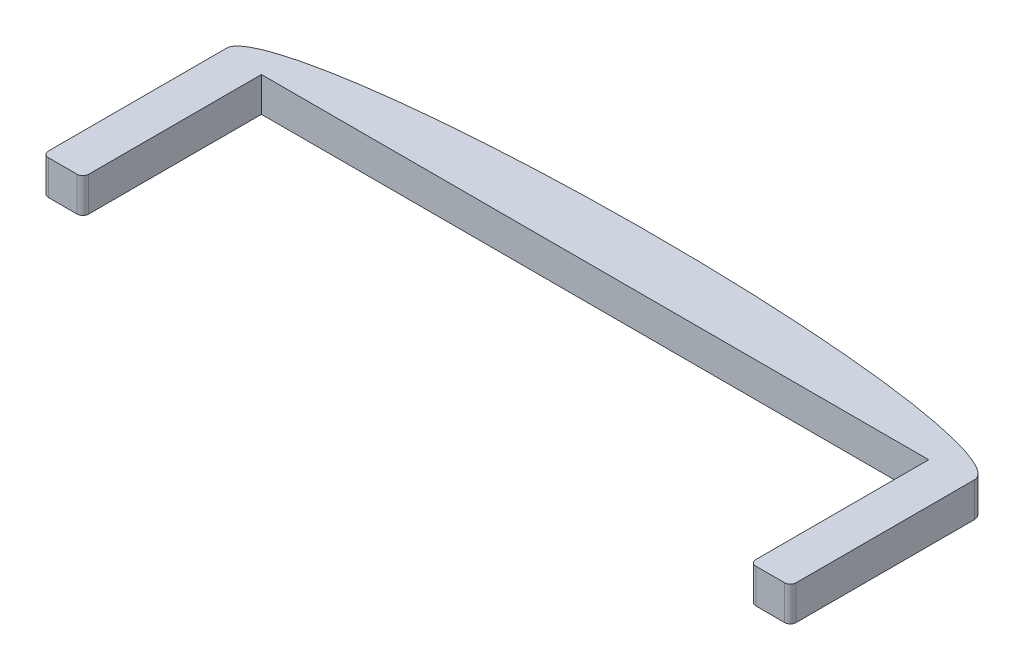
from build123d import *

# Parameters (mm, degrees)
BOSS_EXTRUDE1_DEPTH = 3
CUT_EXTRUDE1_DEPTH  = 4.0000001
SKETCH3_R           = 1.0922
CUT_EXTRUDE2_DEPTH  = 4.0000001
FILLET1_R           = 5
FILLET2_R           = 0.5
CUT_EXTRUDE3_DEPTH  = 4.0000001
FILLET3_R           = 0.5


with BuildPart() as part:
    # Sketch1 → Boss-Extrude1 (new body)
    with BuildSketch(Plane(origin=(0, 0, 0), x_dir=(1, 0, 0), z_dir=(0, 1, 0))):
        with BuildLine():
            Line((0, 0), (-32.5, 0))
            Line((-32.5, 0), (-32.5, 16))
            add(Edge.make_bspline(
                [(0, 20.5), (-32.5, 20.5), (-32.5, 16)],
                knots=[4.71238898, 4.71238898, 4.71238898, 6.283185307, 6.283185307, 6.283185307], degree=2, weights=[1, 0.707106781, 1]))
            Line((0, 20.5), (0, 16))
            Line((0, 16), (0, 0))
        make_face()
    boss_extrude1 = extrude(amount=BOSS_EXTRUDE1_DEPTH)

    # Mirror1: Boss-Extrude1 across plane
    add(boss_extrude1.mirror(Plane(origin=(0, 3, -16), x_dir=(0, 0, 1), z_dir=(-1, 0, 0))))

    # Sketch2 → Cut-Extrude1 (cut, through all)
    with BuildSketch(Plane(origin=(0, 3, 0), x_dir=(1, 0, 0), z_dir=(0, 1, 0))):
        with BuildLine():
            Line((0, 10.25), (0, 12.5))
            add(Edge.make_bspline(
                [(0, 12.5), (-20.26, 12.5), (-20.26, 10.25)],
                knots=[4.71238898, 4.71238898, 4.71238898, 6.283185307, 6.283185307, 6.283185307], degree=2, weights=[1, 0.707106781, 1]))
            Line((-20.26, 10.25), (-20.26, 0))
            Line((-20.26, 0), (0, 0))
            Line((0, 0), (0, 10.25))
        make_face()
        with BuildLine():
            Line((20.26, 0), (20.26, 10.25))
            add(Edge.make_bspline(
                [(20.26, 10.25), (20.26, 12.5), (0, 12.5)],
                knots=[3.141592654, 3.141592654, 3.141592654, 4.71238898, 4.71238898, 4.71238898], degree=2, weights=[1, 0.707106781, 1]))
            Line((0, 12.5), (0, 10.25))
            Line((0, 10.25), (0, 0))
            Line((0, 0), (20.26, 0))
        make_face()
    extrude(amount=-CUT_EXTRUDE1_DEPTH, mode=Mode.SUBTRACT)

    # Sketch3 → Cut-Extrude2 (cut, through all)
    with BuildSketch(Plane.XZ):
        with Locations((25.46, -4.3615)):
            Circle(SKETCH3_R)
        with Locations((-25.34, -4.3615)):
            Circle(SKETCH3_R)
    extrude(amount=-CUT_EXTRUDE2_DEPTH, mode=Mode.SUBTRACT)

    # Fillet1
    fillet1_edges = [part.edges().sort_by_distance(p)[0] for p in [
        (20.26, 1.5, 0),
        (-20.26, 1.5, 0),
    ]]
    fillet(fillet1_edges, radius=FILLET1_R)

    # Fillet2
    fillet2_edges = [part.edges().sort_by_distance(p)[0] for p in [
        (32.5, 1.5, 0),
        (-32.5, 1.5, 0),
    ]]
    fillet(fillet2_edges, radius=FILLET2_R)

    # Sketch4 → Cut-Extrude3 (cut, through all)
    with BuildSketch(Plane.XZ):
        Polygon((29, -1.8215), (29, 0), (-29, 0), (-29, -1.8215), (-29, -15.5215), (29, -15.5215), align=None)
    extrude(amount=-CUT_EXTRUDE3_DEPTH, mode=Mode.SUBTRACT)

    # Fillet3
    fillet3_edges = [part.edges().sort_by_distance(p)[0] for p in [
        (-29, 1.5, 0),
        (29, 1.5, 0),
    ]]
    fillet(fillet3_edges, radius=FILLET3_R)


solid = part.part
